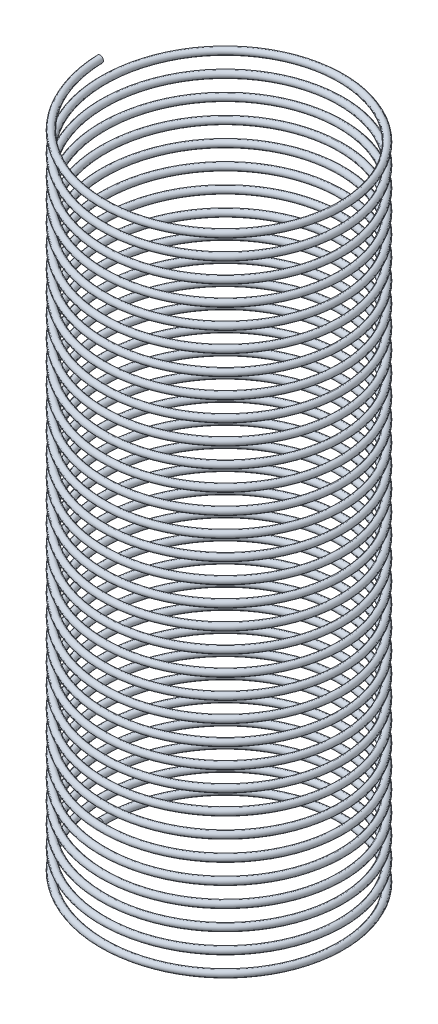
from build123d import *

# Parameters (mm, degrees)
SWEEP1_PITCH       = 3
SWEEP1_HEIGHT      = 99
SWEEP1_RADIUS      = 17.810135555
SWEEP1_START_ANGLE = -90
SKETCH4_R          = 0.5


with BuildPart() as part:
    # Sweep1: sweep along a helix
    with BuildLine() as sweep1_path:
        add(Helix(SWEEP1_PITCH, SWEEP1_HEIGHT, SWEEP1_RADIUS, center=(0, 0, 0), direction=(0, 1, 0), lefthand=True, mode=Mode.PRIVATE).rotate(Axis((0, 0, 0), (0, 1, 0)), SWEEP1_START_ANGLE))
    # Sketch4 → Sweep1 (sweep)
    with BuildSketch(Plane.XY):
        with Locations((-17.810135555, 0)):
            Circle(SKETCH4_R)
    sweep(path=sweep1_path.line, is_frenet=True)


solid = part.part
